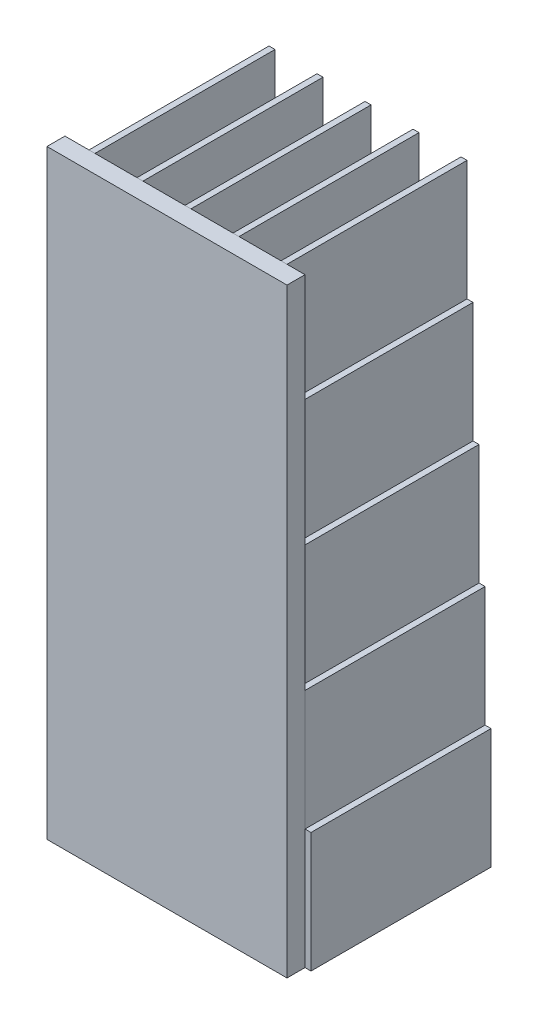
from build123d import *

# Parameters (mm, degrees)
SKETCH1_W              = 1
SKETCH1_H              = 20
BOSS_EXTRUDE1_DEPTH    = 30
BOSS_EXTRUDE1_2_DEPTH  = 30
BOSS_EXTRUDE1_3_DEPTH  = 30
BOSS_EXTRUDE1_4_DEPTH  = 30
BOSS_EXTRUDE1_5_DEPTH  = 30
BOSS_EXTRUDE1_6_DEPTH  = 30
BOSS_EXTRUDE1_7_DEPTH  = 30
BOSS_EXTRUDE1_8_DEPTH  = 30
BOSS_EXTRUDE1_9_DEPTH  = 30
BOSS_EXTRUDE1_10_DEPTH = 30
BOSS_EXTRUDE1_11_DEPTH = 30
BOSS_EXTRUDE1_12_DEPTH = 30
BOSS_EXTRUDE1_13_DEPTH = 30
BOSS_EXTRUDE1_14_DEPTH = 30
BOSS_EXTRUDE1_15_DEPTH = 30
BOSS_EXTRUDE1_16_DEPTH = 30
BOSS_EXTRUDE1_17_DEPTH = 30
BOSS_EXTRUDE1_18_DEPTH = 30
BOSS_EXTRUDE1_19_DEPTH = 30
BOSS_EXTRUDE1_20_DEPTH = 30
BOSS_EXTRUDE1_21_DEPTH = 30
BOSS_EXTRUDE1_22_DEPTH = 30
BOSS_EXTRUDE1_23_DEPTH = 30
BOSS_EXTRUDE1_24_DEPTH = 30
BOSS_EXTRUDE1_25_DEPTH = 30
BOSS_EXTRUDE1_26_DEPTH = 30
BOSS_EXTRUDE1_27_DEPTH = 30
BOSS_EXTRUDE1_28_DEPTH = 30
BOSS_EXTRUDE1_29_DEPTH = 30
BOSS_EXTRUDE1_30_DEPTH = 30
BOSS_EXTRUDE1_31_DEPTH = 30
BOSS_EXTRUDE1_32_DEPTH = 30
BOSS_EXTRUDE1_33_DEPTH = 30
BOSS_EXTRUDE1_34_DEPTH = 30
BOSS_EXTRUDE1_35_DEPTH = 30
BOSS_EXTRUDE1_36_DEPTH = 30
BOSS_EXTRUDE1_37_DEPTH = 30
BOSS_EXTRUDE1_38_DEPTH = 30
BOSS_EXTRUDE1_39_DEPTH = 30
BOSS_EXTRUDE1_40_DEPTH = 30
BOSS_EXTRUDE1_41_DEPTH = 30
SKETCH2_W              = 40
SKETCH2_H              = 100
BOSS_EXTRUDE3_DEPTH    = 3


with BuildPart() as part:
    # Sketch1 → Boss-Extrude1 (new body)
    with BuildSketch(Plane.XY):
        with Locations((-46.033972916, 14.88459588)):
            Rectangle(SKETCH1_W, SKETCH1_H)
    extrude(amount=BOSS_EXTRUDE1_DEPTH)


with BuildPart() as body_2:
    # Sketch1 → Boss-Extrude1 2 (new body)
    with BuildSketch(Plane.XY):
        with Locations((-45.033972916, 34.88459588)):
            Rectangle(SKETCH1_W, SKETCH1_H)
    extrude(amount=BOSS_EXTRUDE1_2_DEPTH)


with BuildPart() as body_3:
    # Sketch1 → Boss-Extrude1 3 (new body)
    with BuildSketch(Plane.XY):
        with Locations((-39.033972916, 34.88459588)):
            Rectangle(SKETCH1_W, SKETCH1_H)
    extrude(amount=BOSS_EXTRUDE1_3_DEPTH)


with BuildPart() as body_4:
    # Sketch1 → Boss-Extrude1 4 (new body)
    with BuildSketch(Plane.XY):
        with Locations((-37.033972916, 34.88459588)):
            Rectangle(SKETCH1_W, SKETCH1_H)
    extrude(amount=BOSS_EXTRUDE1_4_DEPTH)


with BuildPart() as body_5:
    # Sketch1 → Boss-Extrude1 5 (new body)
    with BuildSketch(Plane.XY):
        with Locations((-38.033972916, 14.88459588)):
            Rectangle(SKETCH1_W, SKETCH1_H)
    extrude(amount=BOSS_EXTRUDE1_5_DEPTH)


with BuildPart() as body_6:
    # Sketch1 → Boss-Extrude1 6 (new body)
    with BuildSketch(Plane.XY):
        with Locations((-31.033972916, 34.88459588)):
            Rectangle(SKETCH1_W, SKETCH1_H)
    extrude(amount=BOSS_EXTRUDE1_6_DEPTH)


with BuildPart() as body_7:
    # Sketch1 → Boss-Extrude1 7 (new body)
    with BuildSketch(Plane.XY):
        with Locations((-29.033972916, 34.88459588)):
            Rectangle(SKETCH1_W, SKETCH1_H)
    extrude(amount=BOSS_EXTRUDE1_7_DEPTH)


with BuildPart() as body_8:
    # Sketch1 → Boss-Extrude1 8 (new body)
    with BuildSketch(Plane.XY):
        with Locations((-30.033972916, 14.88459588)):
            Rectangle(SKETCH1_W, SKETCH1_H)
    extrude(amount=BOSS_EXTRUDE1_8_DEPTH)


with BuildPart() as body_9:
    # Sketch1 → Boss-Extrude1 9 (new body)
    with BuildSketch(Plane.XY):
        with Locations((-23.033972916, 34.88459588)):
            Rectangle(SKETCH1_W, SKETCH1_H)
    extrude(amount=BOSS_EXTRUDE1_9_DEPTH)


with BuildPart() as body_10:
    # Sketch1 → Boss-Extrude1 10 (new body)
    with BuildSketch(Plane.XY):
        with Locations((-21.033972916, 34.88459588)):
            Rectangle(SKETCH1_W, SKETCH1_H)
    extrude(amount=BOSS_EXTRUDE1_10_DEPTH)


with BuildPart() as body_11:
    # Sketch1 → Boss-Extrude1 11 (new body)
    with BuildSketch(Plane.XY):
        with Locations((-22.033972916, 14.88459588)):
            Rectangle(SKETCH1_W, SKETCH1_H)
    extrude(amount=BOSS_EXTRUDE1_11_DEPTH)


with BuildPart() as body_12:
    # Sketch1 → Boss-Extrude1 12 (new body)
    with BuildSketch(Plane.XY):
        with Locations((-6.033972916, 14.88459588)):
            Rectangle(SKETCH1_W, SKETCH1_H)
    extrude(amount=BOSS_EXTRUDE1_12_DEPTH)


with BuildPart() as body_13:
    # Sketch1 → Boss-Extrude1 13 (new body)
    with BuildSketch(Plane.XY):
        with Locations((-14.033972916, 14.88459588)):
            Rectangle(SKETCH1_W, SKETCH1_H)
    extrude(amount=BOSS_EXTRUDE1_13_DEPTH)


with BuildPart() as body_14:
    # Sketch1 → Boss-Extrude1 14 (new body)
    with BuildSketch(Plane.XY):
        with Locations((-15.033972916, 34.88459588)):
            Rectangle(SKETCH1_W, SKETCH1_H)
    extrude(amount=BOSS_EXTRUDE1_14_DEPTH)


with BuildPart() as body_15:
    # Sketch1 → Boss-Extrude1 15 (new body)
    with BuildSketch(Plane.XY):
        with Locations((-13.033972916, 34.88459588)):
            Rectangle(SKETCH1_W, SKETCH1_H)
    extrude(amount=BOSS_EXTRUDE1_15_DEPTH)


with BuildPart() as body_16:
    # Sketch1 → Boss-Extrude1 16 (new body)
    with BuildSketch(Plane.XY):
        with Locations((-7.033972916, 34.88459588)):
            Rectangle(SKETCH1_W, SKETCH1_H)
    extrude(amount=BOSS_EXTRUDE1_16_DEPTH)


with BuildPart() as body_17:
    # Sketch1 → Boss-Extrude1 17 (new body)
    with BuildSketch(Plane.XY):
        with Locations((-44.033972916, 54.88459588)):
            Rectangle(SKETCH1_W, SKETCH1_H)
    extrude(amount=BOSS_EXTRUDE1_17_DEPTH)


with BuildPart() as body_18:
    # Sketch1 → Boss-Extrude1 18 (new body)
    with BuildSketch(Plane.XY):
        with Locations((-36.033972916, 54.88459588)):
            Rectangle(SKETCH1_W, SKETCH1_H)
    extrude(amount=BOSS_EXTRUDE1_18_DEPTH)


with BuildPart() as body_19:
    # Sketch1 → Boss-Extrude1 19 (new body)
    with BuildSketch(Plane.XY):
        with Locations((-32.033972916, 54.88459588)):
            Rectangle(SKETCH1_W, SKETCH1_H)
    extrude(amount=BOSS_EXTRUDE1_19_DEPTH)


with BuildPart() as body_20:
    # Sketch1 → Boss-Extrude1 20 (new body)
    with BuildSketch(Plane.XY):
        with Locations((-43.033972916, 74.88459588)):
            Rectangle(SKETCH1_W, SKETCH1_H)
    extrude(amount=BOSS_EXTRUDE1_20_DEPTH)


with BuildPart() as body_21:
    # Sketch1 → Boss-Extrude1 21 (new body)
    with BuildSketch(Plane.XY):
        with Locations((-41.033972916, 74.88459588)):
            Rectangle(SKETCH1_W, SKETCH1_H)
    extrude(amount=BOSS_EXTRUDE1_21_DEPTH)


with BuildPart() as body_22:
    # Sketch1 → Boss-Extrude1 22 (new body)
    with BuildSketch(Plane.XY):
        with Locations((-35.033972916, 74.88459588)):
            Rectangle(SKETCH1_W, SKETCH1_H)
    extrude(amount=BOSS_EXTRUDE1_22_DEPTH)


with BuildPart() as body_23:
    # Sketch1 → Boss-Extrude1 23 (new body)
    with BuildSketch(Plane.XY):
        with Locations((-33.033972916, 74.88459588)):
            Rectangle(SKETCH1_W, SKETCH1_H)
    extrude(amount=BOSS_EXTRUDE1_23_DEPTH)


with BuildPart() as body_24:
    # Sketch1 → Boss-Extrude1 24 (new body)
    with BuildSketch(Plane.XY):
        with Locations((-28.033972916, 54.88459588)):
            Rectangle(SKETCH1_W, SKETCH1_H)
    extrude(amount=BOSS_EXTRUDE1_24_DEPTH)


with BuildPart() as body_25:
    # Sketch1 → Boss-Extrude1 25 (new body)
    with BuildSketch(Plane.XY):
        with Locations((-27.033972916, 74.88459588)):
            Rectangle(SKETCH1_W, SKETCH1_H)
    extrude(amount=BOSS_EXTRUDE1_25_DEPTH)


with BuildPart() as body_26:
    # Sketch1 → Boss-Extrude1 26 (new body)
    with BuildSketch(Plane.XY):
        with Locations((-25.033972916, 74.88459588)):
            Rectangle(SKETCH1_W, SKETCH1_H)
    extrude(amount=BOSS_EXTRUDE1_26_DEPTH)


with BuildPart() as body_27:
    # Sketch1 → Boss-Extrude1 27 (new body)
    with BuildSketch(Plane.XY):
        with Locations((-24.033972916, 54.88459588)):
            Rectangle(SKETCH1_W, SKETCH1_H)
    extrude(amount=BOSS_EXTRUDE1_27_DEPTH)


with BuildPart() as body_28:
    # Sketch1 → Boss-Extrude1 28 (new body)
    with BuildSketch(Plane.XY):
        with Locations((-20.033972916, 54.88459588)):
            Rectangle(SKETCH1_W, SKETCH1_H)
    extrude(amount=BOSS_EXTRUDE1_28_DEPTH)


with BuildPart() as body_29:
    # Sketch1 → Boss-Extrude1 29 (new body)
    with BuildSketch(Plane.XY):
        with Locations((-19.033972916, 74.88459588)):
            Rectangle(SKETCH1_W, SKETCH1_H)
    extrude(amount=BOSS_EXTRUDE1_29_DEPTH)


with BuildPart() as body_30:
    # Sketch1 → Boss-Extrude1 30 (new body)
    with BuildSketch(Plane.XY):
        with Locations((-17.033972916, 74.88459588)):
            Rectangle(SKETCH1_W, SKETCH1_H)
    extrude(amount=BOSS_EXTRUDE1_30_DEPTH)


with BuildPart() as body_31:
    # Sketch1 → Boss-Extrude1 31 (new body)
    with BuildSketch(Plane.XY):
        with Locations((-16.033972916, 54.88459588)):
            Rectangle(SKETCH1_W, SKETCH1_H)
    extrude(amount=BOSS_EXTRUDE1_31_DEPTH)


with BuildPart() as body_32:
    # Sketch1 → Boss-Extrude1 32 (new body)
    with BuildSketch(Plane.XY):
        with Locations((-12.033972916, 54.88459588)):
            Rectangle(SKETCH1_W, SKETCH1_H)
    extrude(amount=BOSS_EXTRUDE1_32_DEPTH)


with BuildPart() as body_33:
    # Sketch1 → Boss-Extrude1 33 (new body)
    with BuildSketch(Plane.XY):
        with Locations((-11.033972916, 74.88459588)):
            Rectangle(SKETCH1_W, SKETCH1_H)
    extrude(amount=BOSS_EXTRUDE1_33_DEPTH)


with BuildPart() as body_34:
    # Sketch1 → Boss-Extrude1 34 (new body)
    with BuildSketch(Plane.XY):
        with Locations((-9.033972916, 74.88459588)):
            Rectangle(SKETCH1_W, SKETCH1_H)
    extrude(amount=BOSS_EXTRUDE1_34_DEPTH)


with BuildPart() as body_35:
    # Sketch1 → Boss-Extrude1 35 (new body)
    with BuildSketch(Plane.XY):
        with Locations((-8.033972916, 54.88459588)):
            Rectangle(SKETCH1_W, SKETCH1_H)
    extrude(amount=BOSS_EXTRUDE1_35_DEPTH)


with BuildPart() as body_36:
    # Sketch1 → Boss-Extrude1 36 (new body)
    with BuildSketch(Plane.XY):
        with Locations((-42.033972916, 94.88459588)):
            Rectangle(SKETCH1_W, SKETCH1_H)
    extrude(amount=BOSS_EXTRUDE1_36_DEPTH)


with BuildPart() as body_37:
    # Sketch1 → Boss-Extrude1 37 (new body)
    with BuildSketch(Plane.XY):
        with Locations((-34.033972916, 94.88459588)):
            Rectangle(SKETCH1_W, SKETCH1_H)
    extrude(amount=BOSS_EXTRUDE1_37_DEPTH)


with BuildPart() as body_38:
    # Sketch1 → Boss-Extrude1 38 (new body)
    with BuildSketch(Plane.XY):
        with Locations((-26.033972916, 94.88459588)):
            Rectangle(SKETCH1_W, SKETCH1_H)
    extrude(amount=BOSS_EXTRUDE1_38_DEPTH)


with BuildPart() as body_39:
    # Sketch1 → Boss-Extrude1 39 (new body)
    with BuildSketch(Plane.XY):
        with Locations((-18.033972916, 94.88459588)):
            Rectangle(SKETCH1_W, SKETCH1_H)
    extrude(amount=BOSS_EXTRUDE1_39_DEPTH)


with BuildPart() as body_40:
    # Sketch1 → Boss-Extrude1 40 (new body)
    with BuildSketch(Plane.XY):
        with Locations((-10.033972916, 94.88459588)):
            Rectangle(SKETCH1_W, SKETCH1_H)
    extrude(amount=BOSS_EXTRUDE1_40_DEPTH)


with BuildPart() as body_41:
    # Sketch1 → Boss-Extrude1 41 (new body)
    with BuildSketch(Plane.XY):
        with Locations((-40.033972916, 54.88459588)):
            Rectangle(SKETCH1_W, SKETCH1_H)
    extrude(amount=BOSS_EXTRUDE1_41_DEPTH)


with BuildPart() as body_42:
    # Sketch2 → Boss-Extrude3 (new body)
    with BuildSketch(Plane.XY.offset(30)):
        with Locations((-26.533972916, 54.88459588)):
            Rectangle(SKETCH2_W, SKETCH2_H)
    extrude(amount=BOSS_EXTRUDE3_DEPTH)


solid = Compound([part.part, body_2.part, body_3.part, body_4.part, body_5.part, body_6.part, body_7.part, body_8.part, body_9.part, body_10.part, body_11.part, body_12.part, body_13.part, body_14.part, body_15.part, body_16.part, body_17.part, body_18.part, body_19.part, body_20.part, body_21.part, body_22.part, body_23.part, body_24.part, body_25.part, body_26.part, body_27.part, body_28.part, body_29.part, body_30.part, body_31.part, body_32.part, body_33.part, body_34.part, body_35.part, body_36.part, body_37.part, body_38.part, body_39.part, body_40.part, body_41.part, body_42.part])
